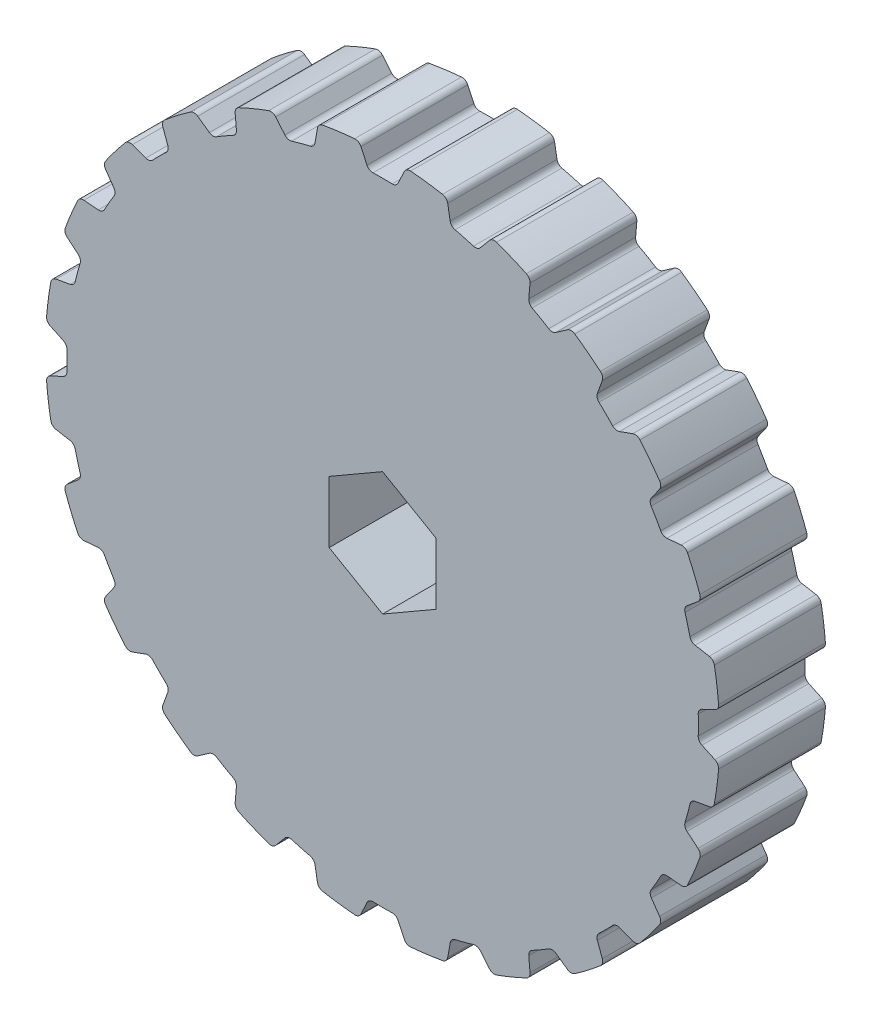
from build123d import *

# Parameters (mm, degrees)
SKETCH3_R                = 20.039170615
BOSS_EXTRUDE1_DEPTH      = 6.35
CUT_EXTRUDE1_DEPTH       = 30.042369357
FILLET1_R                = 0.381
CIRPATTERN1_COUNT        = 24
FILLET1_OF_CIRPATTERN1_R = 0.381


with BuildPart() as part:
    # Sketch3 → Boss-Extrude1 (new body)
    with BuildSketch(Plane.XY):
        Circle(SKETCH3_R)
        Polygon((0, 3.666174209), (-3.175, 1.833087105), (-3.175, -1.833087105), (0, -3.666174209), (3.175, -1.833087105), (3.175, 1.833087105), align=None, mode=Mode.SUBTRACT)
    extrude(amount=BOSS_EXTRUDE1_DEPTH)

    # Sketch4 → Cut-Extrude1 (cut, through all)
    with BuildSketch(Plane.XY.offset(6.35)):
        with BuildLine():
            ThreePointArc((1.397, 19.990416452), (0, 20.039170615), (-1.397, 19.990416452))
            Line((-1.397, 19.990416452), (-0.819183695, 18.751285387))
            ThreePointArc((-0.819183695, 18.751285387), (0, 18.769170615), (0.819183695, 18.751285387))
            Line((0.819183695, 18.751285387), (1.397, 19.990416452))
        make_face()
    cut_extrude1 = extrude(amount=-CUT_EXTRUDE1_DEPTH, mode=Mode.SUBTRACT)

    # Fillet1
    fillet1_edges = [part.edges().sort_by_distance(p)[0] for p in [
        (-0.819183695, 18.751285387, 3.175),
        (-1.397, 19.990416452, 3.175),
        (0.819183695, 18.751285387, 3.175),
        (1.397, 19.990416452, 3.175),
    ]]
    fillet(fillet1_edges, radius=FILLET1_R)

    # CirPattern1: Cut-Extrude1 ×24 about axis
    cirpattern1_axis = Axis((0, 0, 0), (0, 0, -1))
    for i in range(1, CIRPATTERN1_COUNT):
        add(cut_extrude1.rotate(cirpattern1_axis, i * 360 / CIRPATTERN1_COUNT), mode=Mode.SUBTRACT)

    # Fillet1 of CirPattern1
    fillet1_of_cirpattern1_edges = [part.edges().sort_by_distance(p)[0] for p in [
        (4.061919091, 18.324371173, 3.175),
        (3.824502118, 19.670829736, 3.175),
        (5.644460465, 17.900330489, 3.175),
        (6.523298877, 18.947689324, 3.175),
        (8.666208803, 16.648681346, 3.175),
        (8.785370737, 18.01070848, 3.175),
        (10.085076583, 15.829497651, 3.175),
        (11.205045715, 16.61370848, 3.175),
        (12.679910707, 13.838411398, 3.175),
        (13.147530859, 15.123187205, 3.175),
        (13.838411398, 12.679910707, 3.175),
        (15.123187205, 13.147530859, 3.175),
        (15.829497651, 10.085076583, 3.175),
        (16.61370848, 11.205045715, 3.175),
        (16.648681346, 8.666208803, 3.175),
        (18.01070848, 8.785370737, 3.175),
        (17.900330489, 5.644460465, 3.175),
        (18.947689324, 6.523298877, 3.175),
        (18.324371173, 4.061919091, 3.175),
        (19.670829736, 3.824502118, 3.175),
        (18.751285387, 0.819183695, 3.175),
        (19.990416452, 1.397, 3.175),
        (18.751285387, -0.819183695, 3.175),
        (19.990416452, -1.397, 3.175),
        (18.324371173, -4.061919091, 3.175),
        (19.670829736, -3.824502118, 3.175),
        (17.900330489, -5.644460465, 3.175),
        (18.947689324, -6.523298877, 3.175),
        (16.648681346, -8.666208803, 3.175),
        (18.01070848, -8.785370737, 3.175),
        (15.829497651, -10.085076583, 3.175),
        (16.61370848, -11.205045715, 3.175),
        (13.838411398, -12.679910707, 3.175),
        (15.123187205, -13.147530859, 3.175),
        (12.679910707, -13.838411398, 3.175),
        (13.147530859, -15.123187205, 3.175),
        (10.085076583, -15.829497651, 3.175),
        (11.205045715, -16.61370848, 3.175),
        (8.666208803, -16.648681346, 3.175),
        (8.785370737, -18.01070848, 3.175),
        (5.644460465, -17.900330489, 3.175),
        (6.523298877, -18.947689324, 3.175),
        (4.061919091, -18.324371173, 3.175),
        (3.824502118, -19.670829736, 3.175),
        (0.819183695, -18.751285387, 3.175),
        (1.397, -19.990416452, 3.175),
        (-0.819183695, -18.751285387, 3.175),
        (-1.397, -19.990416452, 3.175),
        (-4.061919091, -18.324371173, 3.175),
        (-3.824502118, -19.670829736, 3.175),
        (-5.644460465, -17.900330489, 3.175),
        (-6.523298877, -18.947689324, 3.175),
        (-8.666208803, -16.648681346, 3.175),
        (-8.785370737, -18.01070848, 3.175),
        (-10.085076583, -15.829497651, 3.175),
        (-11.205045715, -16.61370848, 3.175),
        (-12.679910707, -13.838411398, 3.175),
        (-13.147530859, -15.123187205, 3.175),
        (-13.838411398, -12.679910707, 3.175),
        (-15.123187205, -13.147530859, 3.175),
        (-15.829497651, -10.085076583, 3.175),
        (-16.61370848, -11.205045715, 3.175),
        (-16.648681346, -8.666208803, 3.175),
        (-18.01070848, -8.785370737, 3.175),
        (-17.900330489, -5.644460465, 3.175),
        (-18.947689324, -6.523298877, 3.175),
        (-18.324371173, -4.061919091, 3.175),
        (-19.670829736, -3.824502118, 3.175),
        (-18.751285387, -0.819183695, 3.175),
        (-19.990416452, -1.397, 3.175),
        (-18.751285387, 0.819183695, 3.175),
        (-19.990416452, 1.397, 3.175),
        (-18.324371173, 4.061919091, 3.175),
        (-19.670829736, 3.824502118, 3.175),
        (-17.900330489, 5.644460465, 3.175),
        (-18.947689324, 6.523298877, 3.175),
        (-16.648681346, 8.666208803, 3.175),
        (-18.01070848, 8.785370737, 3.175),
        (-15.829497651, 10.085076583, 3.175),
        (-16.61370848, 11.205045715, 3.175),
        (-13.838411398, 12.679910707, 3.175),
        (-15.123187205, 13.147530859, 3.175),
        (-12.679910707, 13.838411398, 3.175),
        (-13.147530859, 15.123187205, 3.175),
        (-10.085076583, 15.829497651, 3.175),
        (-11.205045715, 16.61370848, 3.175),
        (-8.666208803, 16.648681346, 3.175),
        (-8.785370737, 18.01070848, 3.175),
        (-5.644460465, 17.900330489, 3.175),
        (-6.523298877, 18.947689324, 3.175),
        (-4.061919091, 18.324371173, 3.175),
        (-3.824502118, 19.670829736, 3.175),
    ]]
    fillet(fillet1_of_cirpattern1_edges, radius=FILLET1_OF_CIRPATTERN1_R)


solid = part.part
